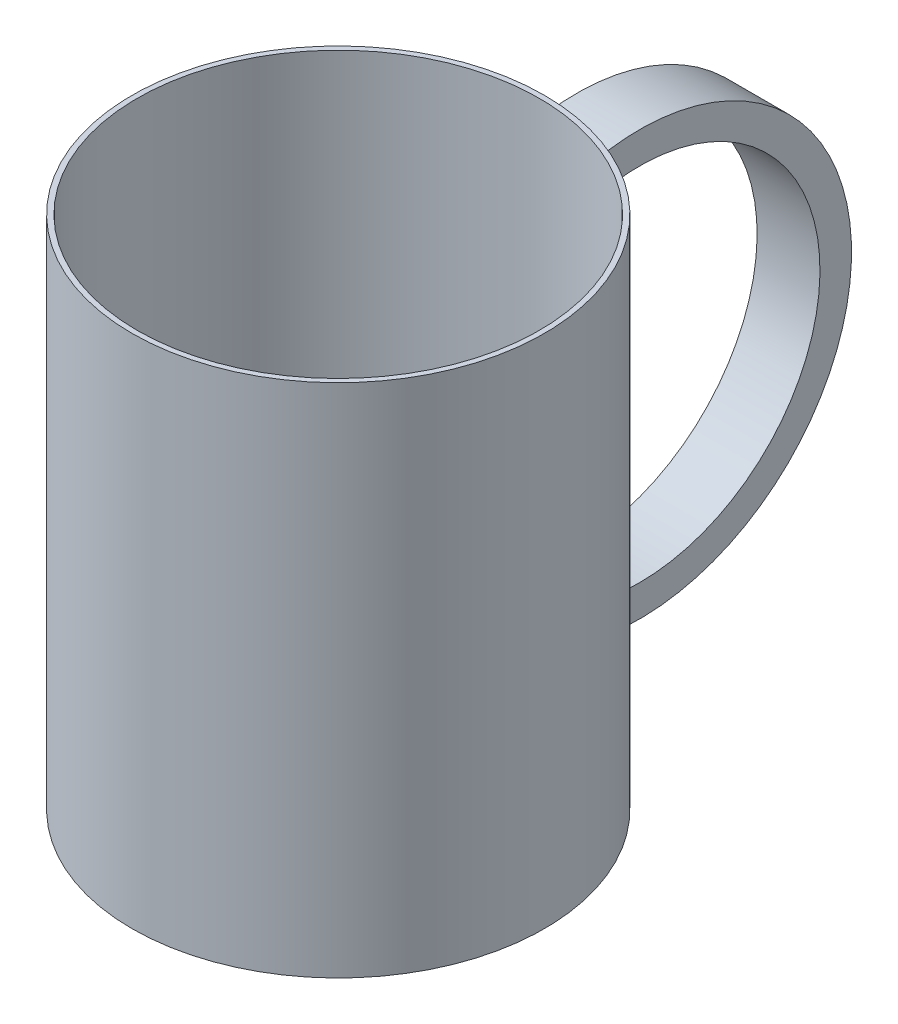
from build123d import *

# Parameters (mm, degrees)
SKETCH3_W               = 40
SKETCH3_H               = 100
SKETCH8_W               = 12.19641385
SKETCH8_H               = 6.117380224
SKETCH10_R              = 39
CUT_EXTRUDE1_DEPTH      = 50
CUT_EXTRUDE1_DEPTH_BACK = 40


with BuildPart() as part:
    # Sketch3 → Revolve2 (revolve)
    with BuildSketch(Plane(origin=(0, 0, 0), x_dir=(0, 0, -1), z_dir=(1, 0, 0))):
        with Locations((20, 0)):
            Rectangle(SKETCH3_W, SKETCH3_H)
    revolve(axis=Axis((0, -50, 0), (0, 1, 0)))

    # Sweep1: sweep along a path in Sketch6
    with BuildLine(Plane(origin=(0, 0, 0), x_dir=(0, 0, -1), z_dir=(1, 0, 0))) as sweep1_path:
        CenterArc((52.344992787, 0), 38.057835552, 0, 360)
    # Sketch8 → Sweep1 (sweep)
    with BuildSketch(Plane(origin=(0, 36, -40), x_dir=(-1, 0, 0), z_dir=(0, 0.324374537, -0.945928729))):
        Rectangle(SKETCH8_W, SKETCH8_H)
    sweep(path=sweep1_path.line)

    # Sketch10 → Cut-Extrude1 (cut, two sides)
    with BuildSketch(Plane(origin=(0, 0, 0), x_dir=(1, 0, 0), z_dir=(0, 1, 0))) as cut_extrude1_sk:
        Circle(SKETCH10_R)
    extrude(amount=CUT_EXTRUDE1_DEPTH, mode=Mode.SUBTRACT)
    extrude(cut_extrude1_sk.sketch, amount=-CUT_EXTRUDE1_DEPTH_BACK, mode=Mode.SUBTRACT)


solid = part.part
